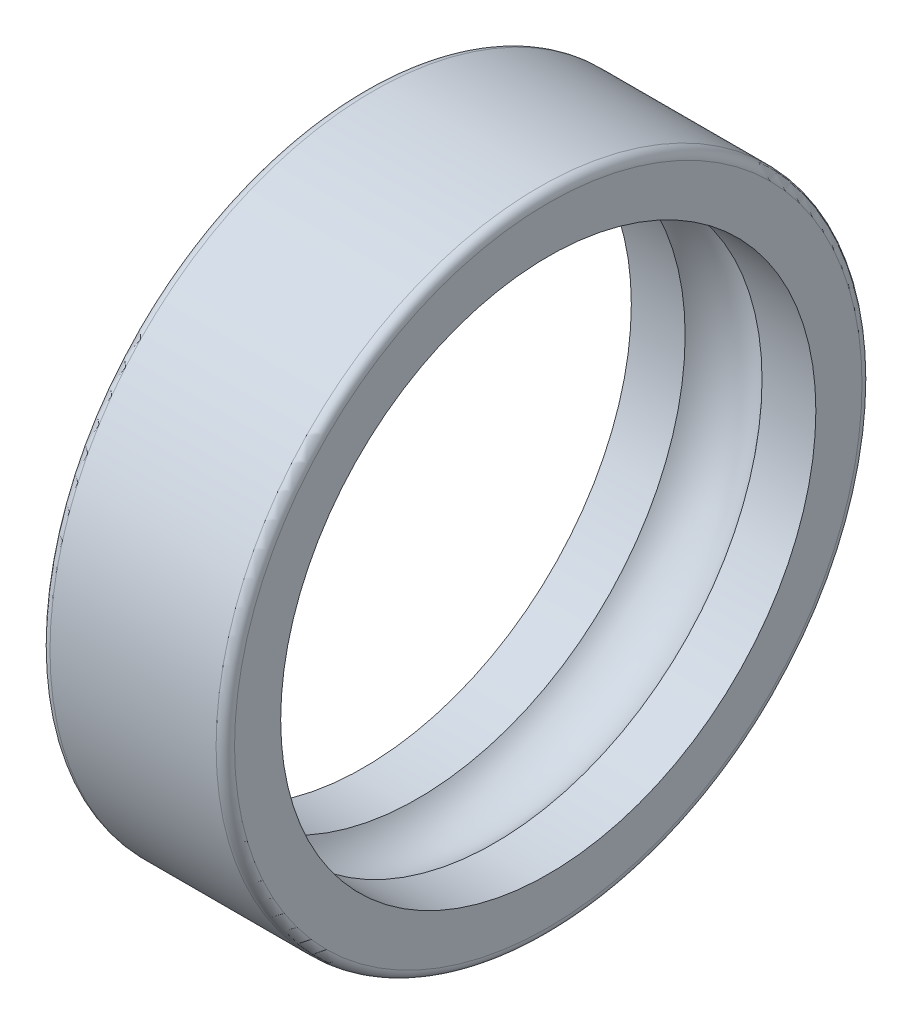
from build123d import *

# Parameters (mm, degrees)
FILLET1_R = 0.6


with BuildPart() as part:
    # Sketch1 → Revolve1 (revolve)
    with BuildSketch(Plane.XY):
        with BuildLine():
            ThreePointArc((2.5, 5.4), (0, 6.602501564), (-2.5, 5.4))
            Line((-2.5, 5.4), (-6, 5.4))
            Line((-6, 5.4), (-6, 9))
            Line((-6, 9), (6, 9))
            Line((6, 9), (6, 5.4))
            Line((6, 5.4), (2.5, 5.4))
        make_face()
    revolve(axis=Axis((6, -12, 0), (-1, 0, 0)))

    # Fillet1
    fillet1_edges = [part.edges().sort_by_distance(p)[0] for p in [
        (-6, -33, 0),
        (6, -33, 0),
    ]]
    fillet(fillet1_edges, radius=FILLET1_R)


solid = part.part
